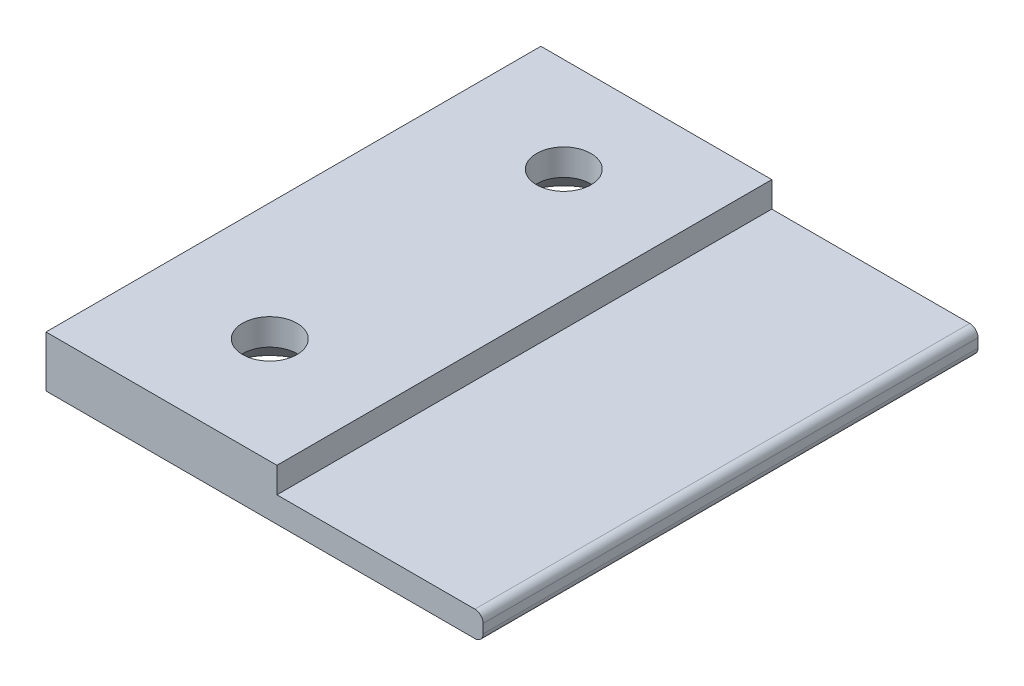
from build123d import *

# Parameters (mm, degrees)
BOSS_EXTRU_1_DEPTH                             = 60
CONG_1_R                                       = 1
FRAISAGE_POUR_VIS_T_TE_FRAIS_E_M62_D           = 6.6
FRAISAGE_POUR_VIS_T_TE_FRAIS_E_M62_DEPTH       = 8
FRAISAGE_POUR_VIS_T_TE_FRAIS_E_M62_CSINK_D     = 12.6
FRAISAGE_POUR_VIS_T_TE_FRAIS_E_M62_CSINK_ANGLE = 90
FRAISAGE_POUR_VIS_T_TE_FRAIS_E_M62_TIP         = 1.982840043


with BuildPart() as part:
    # Esquisse1 → Boss.-Extru.1 (new body)
    with BuildSketch(Plane.XY):
        Polygon((0, 0), (28, 0), (28, -3.1), (53, -3.1), (53, -6.2), (0, -6.2), align=None)
    extrude(amount=BOSS_EXTRU_1_DEPTH)

    # Congé1
    cong_1_edges = [part.edges().sort_by_distance(p)[0] for p in [
        (53, -3.1, 30),
        (53, -6.2, 30),
    ]]
    fillet(cong_1_edges, radius=CONG_1_R)

    # Fraisage pour vis à tête fraisée M62
    with Locations(Plane(origin=(0, -6.2, 0), x_dir=(-1, 0, 0), z_dir=(0, -1, 0))):
        with Locations((-14.293755616, -11.515144287), (-14.293755616, -47.158937793)):
            CounterSinkHole(FRAISAGE_POUR_VIS_T_TE_FRAIS_E_M62_D / 2, FRAISAGE_POUR_VIS_T_TE_FRAIS_E_M62_CSINK_D / 2, depth=FRAISAGE_POUR_VIS_T_TE_FRAIS_E_M62_DEPTH, counter_sink_angle=FRAISAGE_POUR_VIS_T_TE_FRAIS_E_M62_CSINK_ANGLE)
            with Locations((0, 0, -(FRAISAGE_POUR_VIS_T_TE_FRAIS_E_M62_DEPTH + FRAISAGE_POUR_VIS_T_TE_FRAIS_E_M62_TIP / 2))):  # 118° drill point
                Cone(0, FRAISAGE_POUR_VIS_T_TE_FRAIS_E_M62_D / 2, FRAISAGE_POUR_VIS_T_TE_FRAIS_E_M62_TIP, mode=Mode.SUBTRACT)


solid = part.part
